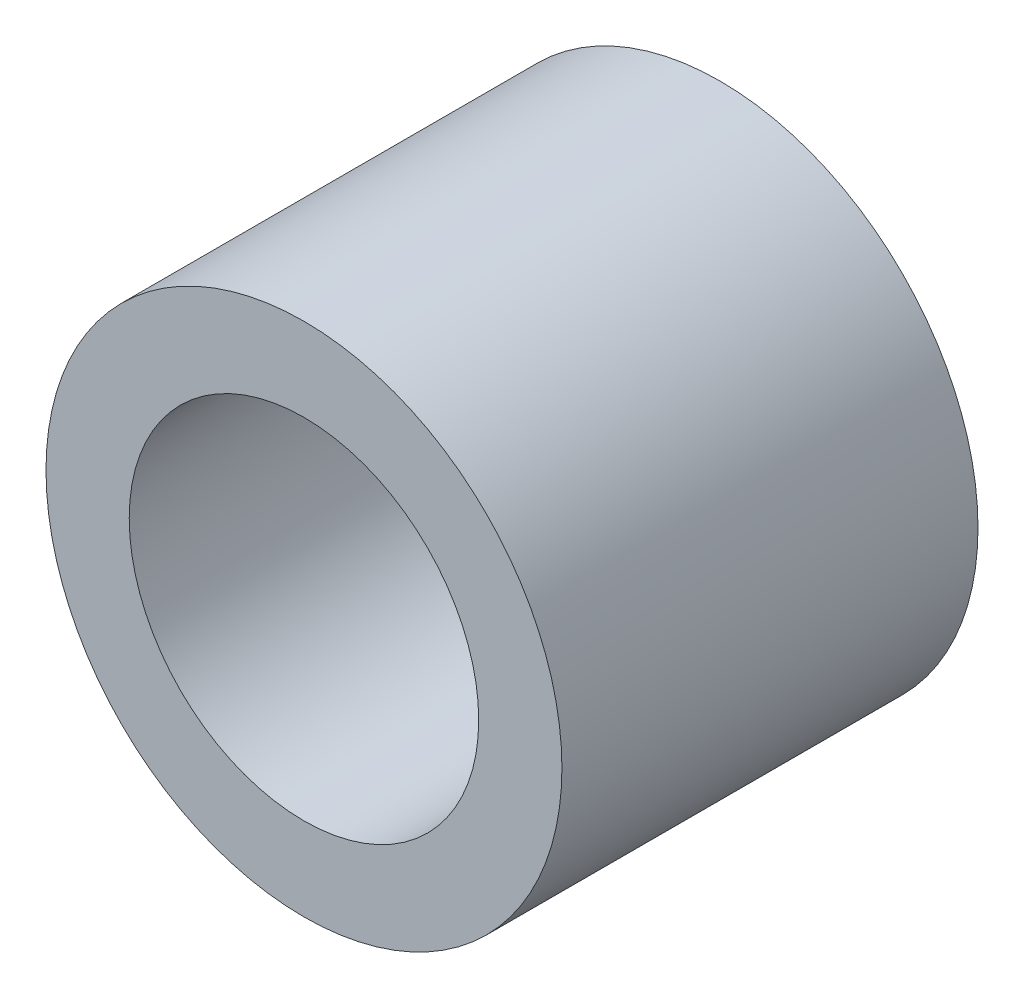
from build123d import *

# Parameters (mm, degrees)
SKETCH1_R           = 3.1
SKETCH1_R_2         = 2.1
BOSS_EXTRUDE1_DEPTH = 5


with BuildPart() as part:
    # Sketch1 → Boss-Extrude1 (new body)
    with BuildSketch(Plane.XY):
        Circle(SKETCH1_R)
        Circle(SKETCH1_R_2, mode=Mode.SUBTRACT)
    extrude(amount=BOSS_EXTRUDE1_DEPTH)


solid = part.part
